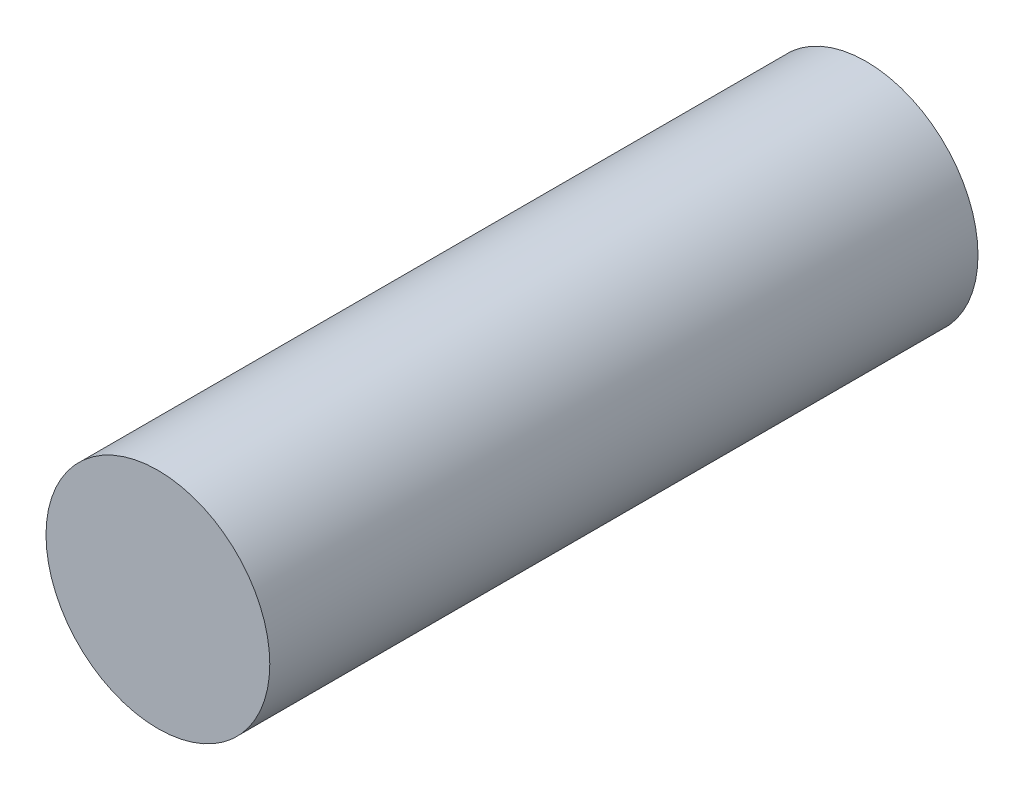
from build123d import *

# Parameters (mm, degrees)
SKETCH1_R           = 7.9
BOSS_EXTRUDE1_DEPTH = 50


with BuildPart() as part:
    # Sketch1 → Boss-Extrude1 (new body)
    with BuildSketch(Plane.XY):
        Circle(SKETCH1_R)
    extrude(amount=BOSS_EXTRUDE1_DEPTH)


solid = part.part
